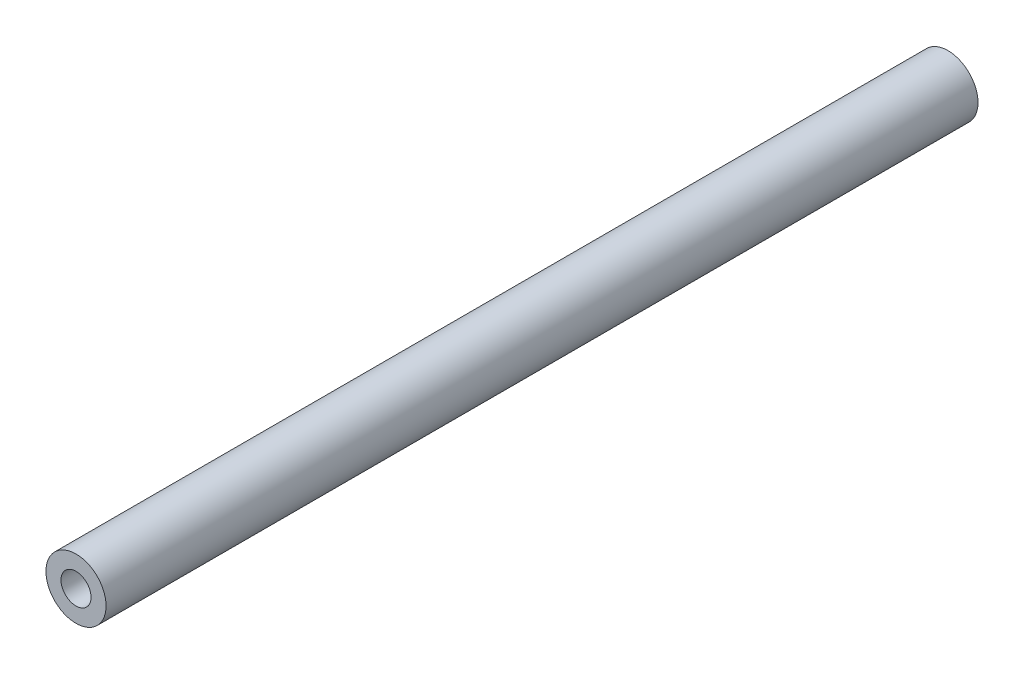
from build123d import *

# Parameters (mm, degrees)
SKETCH1_R           = 10
SKETCH1_R_2         = 5
BOSS_EXTRUDE1_DEPTH = 290


with BuildPart() as part:
    # Sketch1 → Boss-Extrude1 (new body)
    with BuildSketch(Plane.XY):
        Circle(SKETCH1_R)
        Circle(SKETCH1_R_2, mode=Mode.SUBTRACT)
    extrude(amount=BOSS_EXTRUDE1_DEPTH)


solid = part.part
